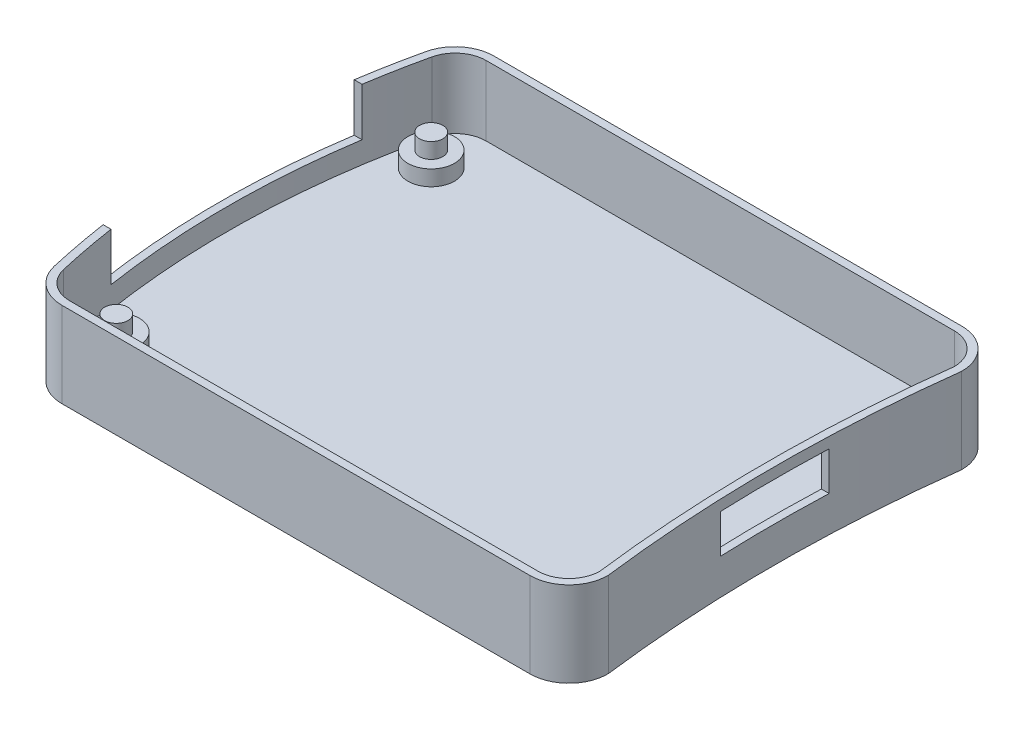
from build123d import *

# Parameters (mm, degrees)
BOSS_EXTRUDE7_DEPTH     = 2
SKETCH8_R               = 3
BOSS_EXTRUDE8_DEPTH     = 2
SKETCH9_R               = 1.5
BOSS_EXTRUDE9_DEPTH     = 2
BOSS_EXTRUDE10_DEPTH    = 9
SKETCH12_W              = 14
SKETCH12_H              = 5
CUT_EXTRUDE5_DEPTH      = 10
CUT_EXTRUDE5_DEPTH_BACK = 10
SKETCH13_W              = 8.729840012
SKETCH13_H              = 32.4
CUT_EXTRUDE6_DEPTH      = 6.2


with BuildPart() as part:
    # Sketch7 → Boss-Extrude7 (new body)
    with BuildSketch(Plane(origin=(0, 0, 0), x_dir=(1, 0, 0), z_dir=(0, 1, 0))):
        with BuildLine():
            Line((30.48, 27.87), (-29.941284627, 27.87))
            ThreePointArc((-29.941284627, 27.87), (-33.058077828, 26.779680312), (-34.815550633, 23.984240056))
            ThreePointArc((-34.815550633, 23.984240056), (-37.522, 0), (-34.815550633, -23.984240056))
            ThreePointArc((-34.815550633, -23.984240056), (-33.058077828, -26.779680312), (-29.941284627, -27.87))
            Line((-29.941284627, -27.87), (30.48, -27.87))
            ThreePointArc((30.48, -27.87), (34.050723427, -26.374261545), (35.489363684, -22.780153375))
            ThreePointArc((35.489363684, -22.780153375), (34.068, 0), (35.489363684, 22.780153375))
            ThreePointArc((35.489363684, 22.780153375), (34.050723427, 26.374261545), (30.48, 27.87))
        make_face()
    extrude(amount=BOSS_EXTRUDE7_DEPTH)

    # Sketch8 → Boss-Extrude8 (add)
    with BuildSketch(Plane(origin=(0, 2, 0), x_dir=(1, 0, 0), z_dir=(0, 1, 0))):
        with Locations((-30.48, 20.32)):
            Circle(SKETCH8_R)
        with Locations((-30.48, -20.32)):
            Circle(SKETCH8_R)
        with Locations((30.48, -22.86)):
            Circle(SKETCH8_R)
        with Locations((30.48, 22.86)):
            Circle(SKETCH8_R)
    extrude(amount=BOSS_EXTRUDE8_DEPTH)

    # Sketch9 → Boss-Extrude9 (add)
    with BuildSketch(Plane(origin=(0, 4, 0), x_dir=(1, 0, 0), z_dir=(0, 1, 0))):
        with Locations((-30.48, 20.32)):
            Circle(SKETCH9_R)
        with Locations((30.48, 22.86)):
            Circle(SKETCH9_R)
        with Locations((30.48, -22.86)):
            Circle(SKETCH9_R)
        with Locations((-30.48, -20.32)):
            Circle(SKETCH9_R)
    extrude(amount=BOSS_EXTRUDE9_DEPTH)

    # Sketch10 → Boss-Extrude10 (add)
    with BuildSketch(Plane(origin=(0, 2, 0), x_dir=(1, 0, 0), z_dir=(0, 1, 0))):
        with BuildLine():
            Line((30.48, 27.87), (-29.941284627, 27.87))
            ThreePointArc((-29.941284627, 27.87), (-33.058077828, 26.779680312), (-34.815550633, 23.984240056))
            ThreePointArc((-34.815550633, 23.984240056), (-37.522, 0), (-34.815550633, -23.984240056))
            ThreePointArc((-34.815550633, -23.984240056), (-33.058077828, -26.779680312), (-29.941284627, -27.87))
            Line((-29.941284627, -27.87), (30.48, -27.87))
            ThreePointArc((30.48, -27.87), (34.050723427, -26.374261545), (35.489363684, -22.780153375))
            ThreePointArc((35.489363684, -22.780153375), (34.068, 0), (35.489363684, 22.780153375))
            ThreePointArc((35.489363684, 22.780153375), (34.050723427, 26.374261545), (30.48, 27.87))
        make_face()
        with BuildLine():
            Line((-29.941284627, -26.87), (30.48, -26.87))
            ThreePointArc((30.48, -26.87), (33.319950466, -25.691038917), (34.489980196, -22.847397183))
            ThreePointArc((34.489980196, -22.847397183), (33.068, 0), (34.489980196, 22.847397183))
            ThreePointArc((34.489980196, 22.847397183), (33.319950466, 25.691038917), (30.48, 26.87))
            Line((30.48, 26.87), (-29.941284627, 26.87))
            ThreePointArc((-29.941284627, 26.87), (-32.434719188, 25.997744249), (-33.840697431, 23.761392045))
            ThreePointArc((-33.840697431, 23.761392045), (-36.522, 0), (-33.840697431, -23.761392045))
            ThreePointArc((-33.840697431, -23.761392045), (-32.434719188, -25.997744249), (-29.941284627, -26.87))
        make_face(mode=Mode.SUBTRACT)
    extrude(amount=BOSS_EXTRUDE10_DEPTH)

    # Sketch12 → Cut-Extrude5 (cut, two sides)
    with BuildSketch(Plane(origin=(34.068, 0, 0), x_dir=(0, 0, -1), z_dir=(1, 0, 0))) as cut_extrude5_sk:
        with Locations((0, 7.1)):
            Rectangle(SKETCH12_W, SKETCH12_H)
    extrude(amount=CUT_EXTRUDE5_DEPTH, mode=Mode.SUBTRACT)
    extrude(cut_extrude5_sk.sketch, amount=-CUT_EXTRUDE5_DEPTH_BACK, mode=Mode.SUBTRACT)

    # Sketch13 → Cut-Extrude6 (cut)
    with BuildSketch(Plane(origin=(0, 11, 0), x_dir=(1, 0, 0), z_dir=(0, 1, 0))):
        with Locations((-37.029964161, 0)):
            Rectangle(SKETCH13_W, SKETCH13_H)
    extrude(amount=-CUT_EXTRUDE6_DEPTH, mode=Mode.SUBTRACT)


solid = part.part
